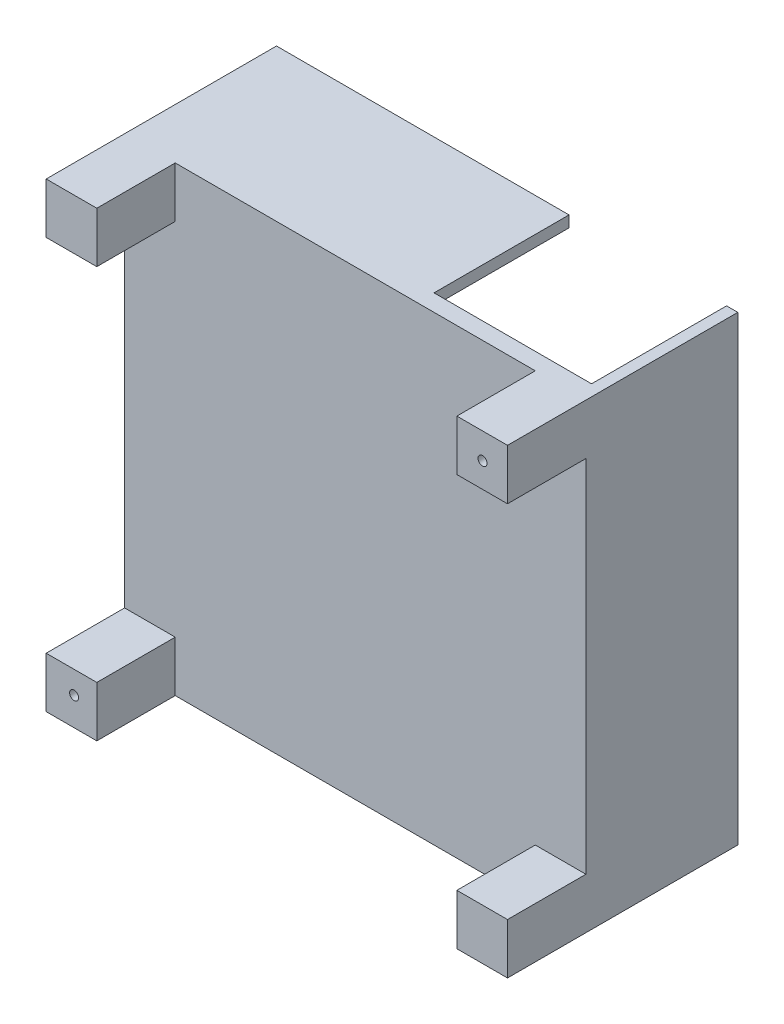
from build123d import *

# Parameters (mm, degrees)
SCHIZZO1_W                   = 41
SCHIZZO1_H                   = 41
ESTRUSIONE_ESTRUSIONE1_DEPTH = 1.5
SCHIZZO5_W                   = 4.5
SCHIZZO5_H                   = 4.5
ESTRUSIONE_ESTRUSIONE2_DEPTH = 6.97
SCHIZZO6_W                   = 4.5
SCHIZZO6_H                   = 4.5
ESTRUSIONE_ESTRUSIONE3_DEPTH = 6.97
SCHIZZO7_W                   = 4.5
SCHIZZO7_H                   = 4.5
ESTRUSIONE_ESTRUSIONE4_DEPTH = 6.97
SCHIZZO8_W                   = 4.5
SCHIZZO8_H                   = 4.5
ESTRUSIONE_ESTRUSIONE5_DEPTH = 6.97
SCHIZZO9_W                   = 1
SCHIZZO9_H                   = 41
ESTRUSIONE_ESTRUSIONE6_DEPTH = 12
SCHIZZO10_W                  = 26
SCHIZZO10_H                  = 1
ESTRUSIONE_ESTRUSIONE7_DEPTH = 12
SCHIZZO11_R                  = 0.4
TAGLIO_ESTRUSIONE1_DEPTH     = 10
SCHIZZO12_R                  = 0.4
TAGLIO_ESTRUSIONE2_DEPTH     = 10


with BuildPart() as part:
    # Schizzo1 → Estrusione-Estrusione1 (new body)
    with BuildSketch(Plane.XY):
        with Locations((20.5, 20.5)):
            Rectangle(SCHIZZO1_W, SCHIZZO1_H)
    extrude(amount=ESTRUSIONE_ESTRUSIONE1_DEPTH)

    # Schizzo5 → Estrusione-Estrusione2 (add)
    with BuildSketch(Plane.XY.offset(1.5)):
        with Locations((2.25, 2.25)):
            Rectangle(SCHIZZO5_W, SCHIZZO5_H)
    extrude(amount=ESTRUSIONE_ESTRUSIONE2_DEPTH)

    # Schizzo6 → Estrusione-Estrusione3 (add)
    with BuildSketch(Plane.XY.offset(1.5)):
        with Locations((38.75, 2.25)):
            Rectangle(SCHIZZO6_W, SCHIZZO6_H)
    extrude(amount=ESTRUSIONE_ESTRUSIONE3_DEPTH)

    # Schizzo7 → Estrusione-Estrusione4 (add)
    with BuildSketch(Plane.XY.offset(1.5)):
        with Locations((2.25, 38.75)):
            Rectangle(SCHIZZO7_W, SCHIZZO7_H)
    extrude(amount=ESTRUSIONE_ESTRUSIONE4_DEPTH)

    # Schizzo8 → Estrusione-Estrusione5 (add)
    with BuildSketch(Plane.XY.offset(1.5)):
        with Locations((38.75, 38.75)):
            Rectangle(SCHIZZO8_W, SCHIZZO8_H)
    extrude(amount=ESTRUSIONE_ESTRUSIONE5_DEPTH)

    # Schizzo9 → Estrusione-Estrusione6 (add)
    with BuildSketch(Plane(origin=(0, 0, 0), x_dir=(-1, 0, 0), z_dir=(0, 0, -1))):
        with Locations((-40.5, 20.5)):
            Rectangle(SCHIZZO9_W, SCHIZZO9_H)
    extrude(amount=ESTRUSIONE_ESTRUSIONE6_DEPTH)

    # Schizzo10 → Estrusione-Estrusione7 (add)
    with BuildSketch(Plane(origin=(0, 0, 0), x_dir=(-1, 0, 0), z_dir=(0, 0, -1))):
        with Locations((-13, 40.5)):
            Rectangle(SCHIZZO10_W, SCHIZZO10_H)
    extrude(amount=ESTRUSIONE_ESTRUSIONE7_DEPTH)

    # Schizzo11 → Taglio-Estrusione1 (cut)
    with BuildSketch(Plane.XY.offset(8.47)):
        with Locations((38.781075858, 38.7)):
            Circle(SCHIZZO11_R)
    extrude(amount=-TAGLIO_ESTRUSIONE1_DEPTH, mode=Mode.SUBTRACT)

    # Schizzo12 → Taglio-Estrusione2 (cut)
    with BuildSketch(Plane.XY.offset(8.47)):
        with Locations((2.481075858, 2.5)):
            Circle(SCHIZZO12_R)
    extrude(amount=-TAGLIO_ESTRUSIONE2_DEPTH, mode=Mode.SUBTRACT)


solid = part.part
